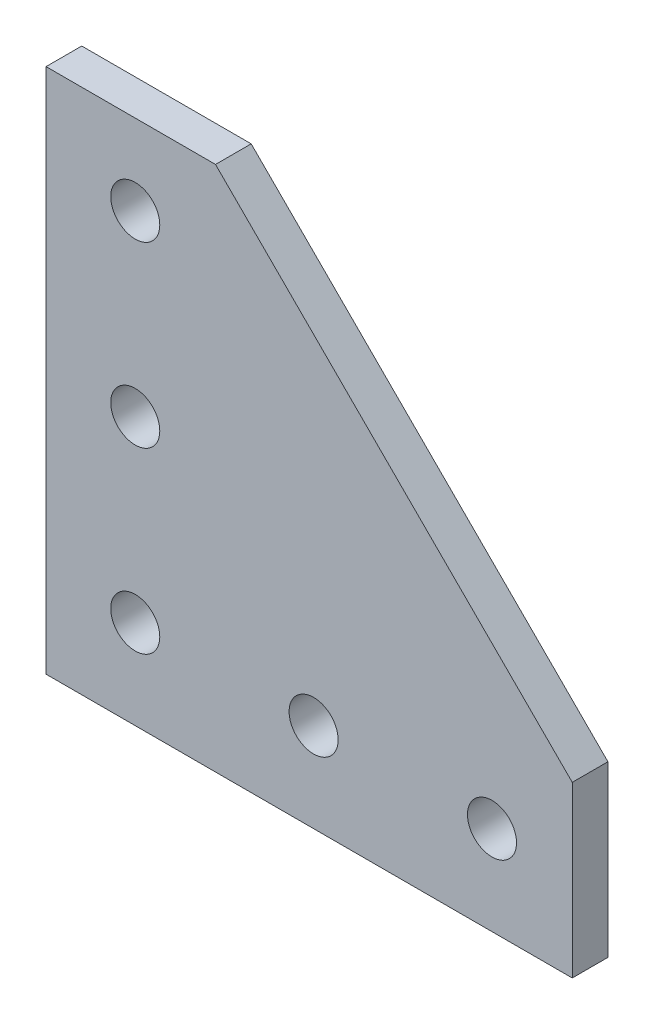
from build123d import *

# Parameters (mm, degrees)
SKETCH1_R           = 2.75
BOSS_EXTRUDE1_DEPTH = 2


with BuildPart() as part:
    # Sketch1 → Boss-Extrude1 (new body, symmetric)
    with BuildSketch(Plane.XY):
        Polygon((0, 0), (0, 59), (19, 59), (59, 19), (59, 0), align=None)
        with Locations((10, 10)):
            Circle(SKETCH1_R, mode=Mode.SUBTRACT)
        with Locations((10, 30)):
            Circle(SKETCH1_R, mode=Mode.SUBTRACT)
        with Locations((10, 50)):
            Circle(SKETCH1_R, mode=Mode.SUBTRACT)
        with Locations((30, 10)):
            Circle(SKETCH1_R, mode=Mode.SUBTRACT)
        with Locations((50, 10)):
            Circle(SKETCH1_R, mode=Mode.SUBTRACT)
    extrude(amount=BOSS_EXTRUDE1_DEPTH, both=True)


solid = part.part
